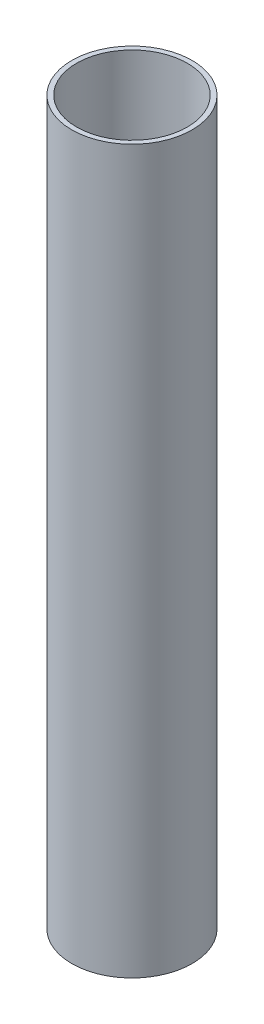
from build123d import *

# Parameters (mm, degrees)
SKETCH_1_R      = 12.5
SKETCH_1_R_2    = 11.5
EXTRUDE_1_DEPTH = 150


with BuildPart() as part:
    # Эскиз1 → Бобышка-Вытянуть1 (new body)
    with BuildSketch(Plane(origin=(0, 0, 0), x_dir=(1, 0, 0), z_dir=(0, 1, 0))):
        Circle(SKETCH_1_R)
        Circle(SKETCH_1_R_2, mode=Mode.SUBTRACT)
    extrude(amount=EXTRUDE_1_DEPTH)


solid = part.part
